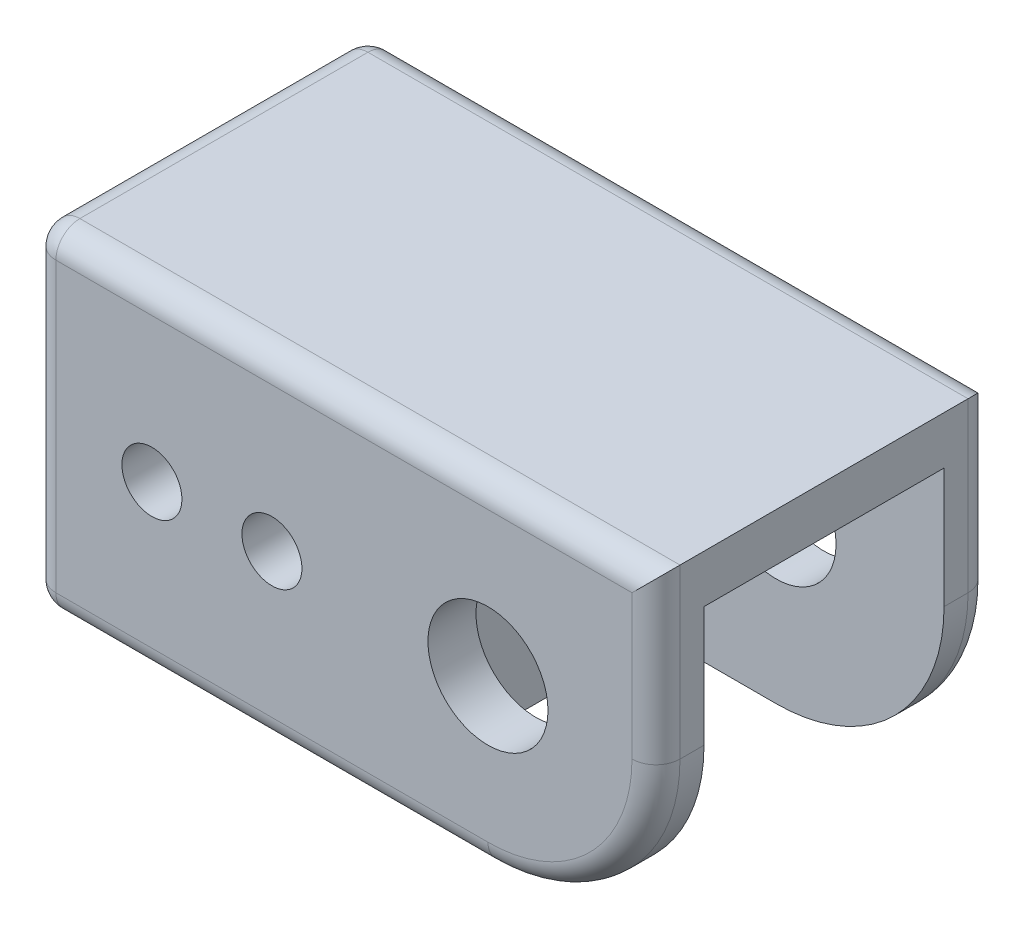
from build123d import *

# Parameters (mm, degrees)
SKETCH1_W               = 66.04
SKETCH1_H               = 35.56
SKETCH1_R               = 6.35
SKETCH1_R_2             = 3.175
BOSS_EXTRUDE1_DEPTH     = 35.56
CUT_EXTRUDE1_DEPTH      = 12.7
CUT_EXTRUDE1_DEPTH_BACK = 12.7
SKETCH3_W               = 25.4
SKETCH3_H               = 25.4
CUT_EXTRUDE2_DEPTH      = 33.02
FILLET1_R               = 17.78
FILLET2_R               = 2.54


with BuildPart() as part:
    # Sketch1 → Boss-Extrude1 (new body)
    with BuildSketch(Plane.XY):
        with Locations((-15.24, 0)):
            Rectangle(SKETCH1_W, SKETCH1_H)
        Circle(SKETCH1_R, mode=Mode.SUBTRACT)
        with Locations((-35.56, 0)):
            Circle(SKETCH1_R_2, mode=Mode.SUBTRACT)
        with Locations((-22.86, 0)):
            Circle(SKETCH1_R_2, mode=Mode.SUBTRACT)
    extrude(amount=BOSS_EXTRUDE1_DEPTH)

    # Sketch2 → Cut-Extrude1 (cut, two sides)
    with BuildSketch(Plane.XY.offset(17.78)) as cut_extrude1_sk:
        with BuildLine():
            Line((0, 12.7), (17.78, 12.7))
            Line((17.78, 12.7), (17.78, -17.78))
            Line((17.78, -17.78), (-12.7, -17.78))
            Line((-12.7, -17.78), (-12.7, 0))
            ThreePointArc((-12.7, 0), (-8.980256121, 8.980256121), (0, 12.7))
        make_face()
    extrude(amount=CUT_EXTRUDE1_DEPTH, mode=Mode.SUBTRACT)
    extrude(cut_extrude1_sk.sketch, amount=-CUT_EXTRUDE1_DEPTH_BACK, mode=Mode.SUBTRACT)

    # Sketch3 → Cut-Extrude2 (cut)
    with BuildSketch(Plane.ZY.offset(48.26)):
        with Locations((17.78, 0)):
            Rectangle(SKETCH3_W, SKETCH3_H)
    extrude(amount=-CUT_EXTRUDE2_DEPTH, mode=Mode.SUBTRACT)

    # Fillet1
    fillet1_edges = [part.edges().sort_by_distance(p)[0] for p in [
        (17.78, -17.78, 2.54),
        (17.78, -17.78, 33.02),
    ]]
    fillet(fillet1_edges, radius=FILLET1_R)

    # Fillet2
    fillet2_edges = [part.edges().sort_by_distance(p)[0] for p in [
        (-24.13, -17.78, 35.56),
        (-15.24, 17.78, 35.56),
        (-24.13, -17.78, 0),
        (-48.26, 0, 0),
        (-15.24, 17.78, 0),
        (17.78, 8.89, 0),
        (17.78, 8.89, 35.56),
        (12.572358569, -12.572358569, 35.56),
        (12.572358569, -12.572358569, 0),
        (-48.26, -17.78, 17.78),
        (-48.26, 17.78, 17.78),
        (-48.26, 0, 35.56),
    ]]
    fillet(fillet2_edges, radius=FILLET2_R)


solid = part.part
